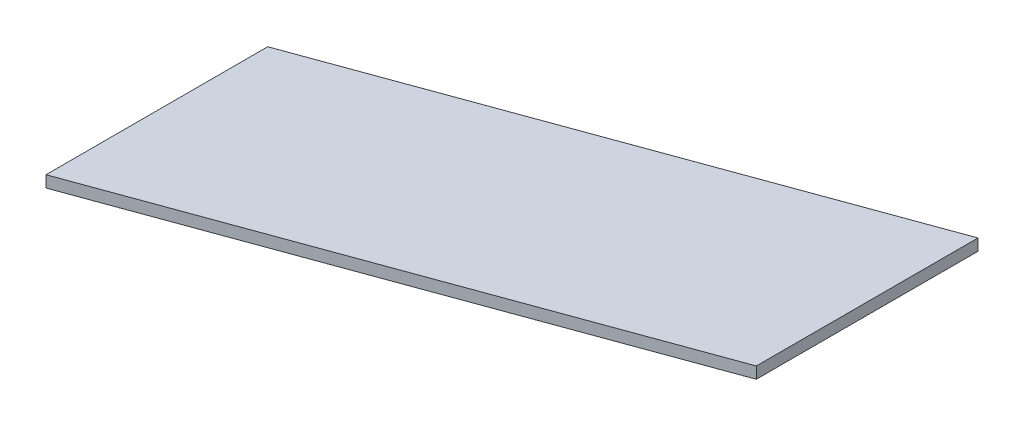
from build123d import *

# Parameters (mm, degrees)
BOSS_EXTRUDE1_DEPTH = 3.175


with BuildPart() as part:
    # Sketch1 → Boss-Extrude1 (new body)
    with BuildSketch(Plane(origin=(0, 0, 0), x_dir=(1, 0, 0), z_dir=(0, 1, 0))):
        Polygon((0, -60.96), (0, 0), (143.209155408, 52.123869843), (143.209155408, -8.836130157), align=None)
    extrude(amount=BOSS_EXTRUDE1_DEPTH)


solid = part.part
